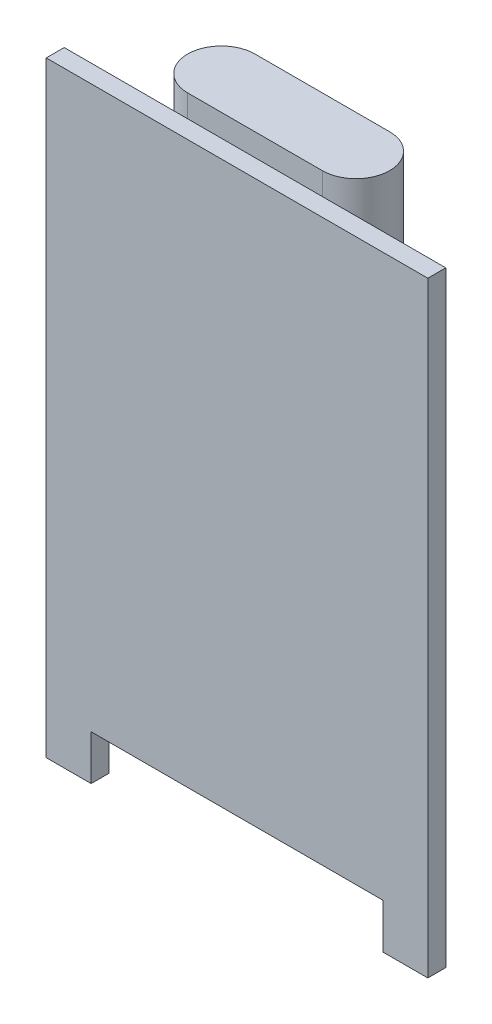
from build123d import *

# Parameters (mm, degrees)
RESSALTO_EXTRUS_O1_DEPTH      = 0.8
RESSALTO_EXTRUS_O2_DEPTH      = 1
RESSALTO_EXTRUS_O2_DEPTH_BACK = 6


with BuildPart() as part:
    # Esboço1 → Ressalto-extrusão1 (new body)
    with BuildSketch(Plane.XY):
        Polygon((8.5, 13.5), (-8.5, 13.5), (-8.5, -13.5), (-6.5, -13.5), (-6.5, -11.5), (6.5, -11.5), (6.5, -13.5), (8.5, -13.5), align=None)
    extrude(amount=RESSALTO_EXTRUS_O1_DEPTH)

    # Esboço3 → Ressalto-extrusão2 (add, two sides)
    with BuildSketch(Plane(origin=(0, 13.5, 0), x_dir=(1, 0, 0), z_dir=(0, 1, 0))) as ressalto_extrus_o2_sk:
        with BuildLine():
            Line((-3, 3), (3, 3))
            ThreePointArc((3, 3), (4.5, 1.5), (3, 0))
            Line((3, 0), (-3, 0))
            ThreePointArc((-3, 0), (-4.5, 1.5), (-3, 3))
        make_face()
    extrude(amount=RESSALTO_EXTRUS_O2_DEPTH)
    extrude(ressalto_extrus_o2_sk.sketch, amount=-RESSALTO_EXTRUS_O2_DEPTH_BACK)


solid = part.part
